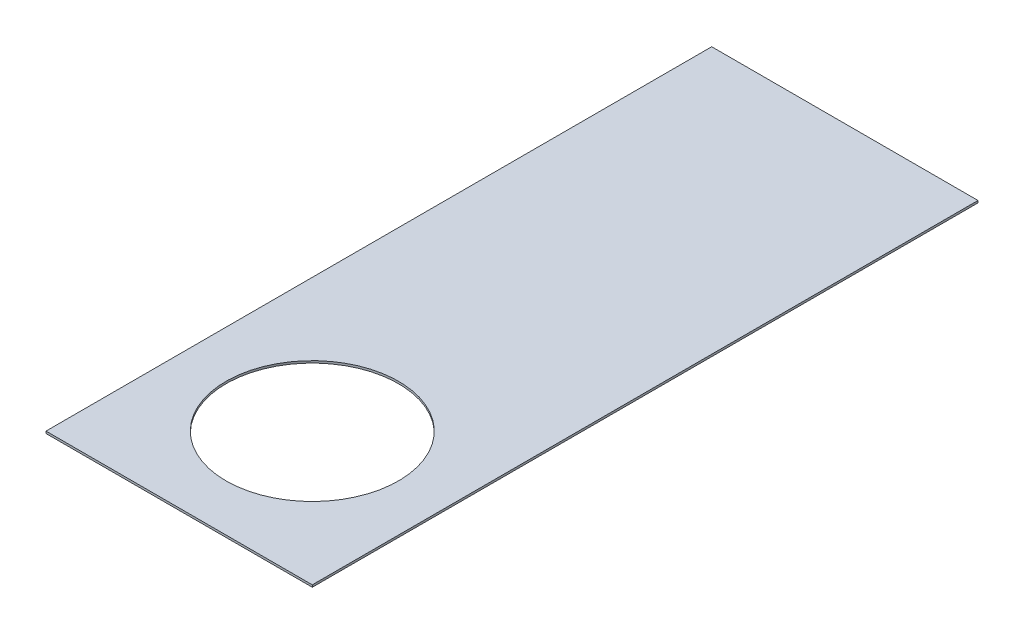
from build123d import *

# Parameters (mm, degrees)
SKETCH1_W             = 3.175
SKETCH1_H             = 7.9375
BOSS_EXTRUDE1_DEPTH   = 0.0254
F_1_CLEARANCE_HOLE1_D = 2.0574


with BuildPart() as part:
    # Sketch1 → Boss-Extrude1 (new body)
    with BuildSketch(Plane(origin=(0, 0, 0), x_dir=(1, 0, 0), z_dir=(0, 1, 0))):
        Rectangle(SKETCH1_W, SKETCH1_H)
    extrude(amount=BOSS_EXTRUDE1_DEPTH)

    # #1 Clearance Hole1 (through all)
    with Locations(Plane(origin=(0, 0.0254, 0), x_dir=(1, 0, 0), z_dir=(0, 1, 0))):
        with Locations((0, -2.38125)):
            Hole(F_1_CLEARANCE_HOLE1_D / 2)


solid = part.part
